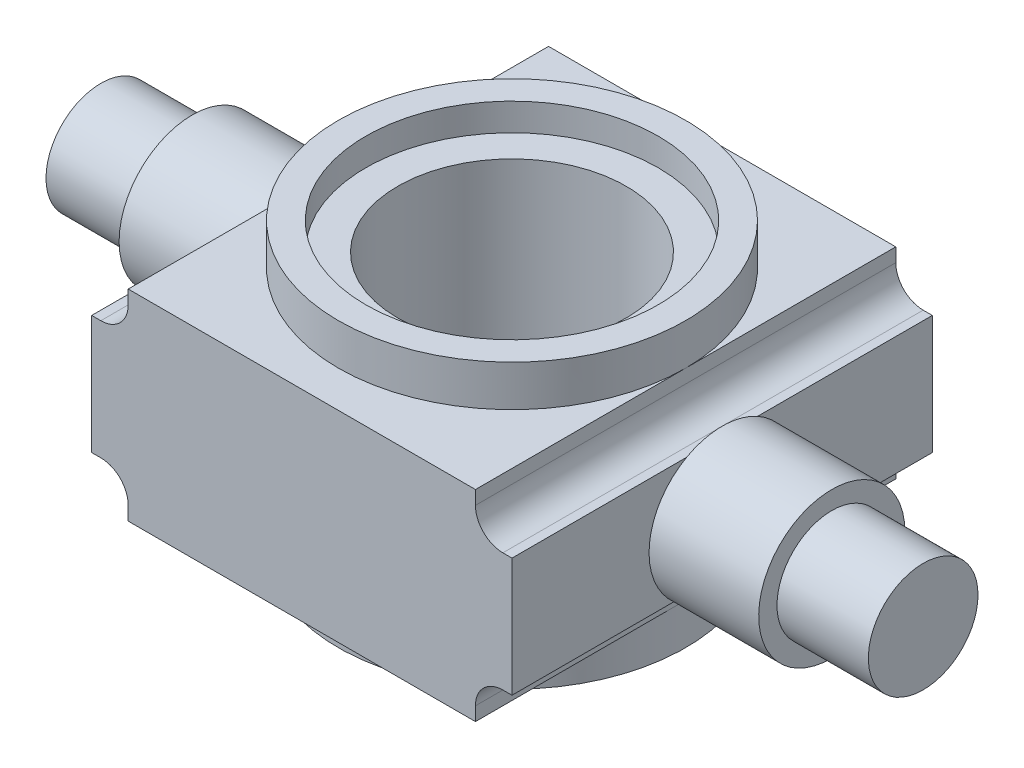
from build123d import *

# Parameters (mm, degrees)
SKETCH1_W           = 46
SKETCH1_H           = 46
BOSS_EXTRUDE1_DEPTH = 22
SKETCH2_R           = 19
BOSS_EXTRUDE4_DEPTH = 4.5
SKETCH5_R           = 19
BOSS_EXTRUDE5_DEPTH = 4.5
SKETCH6_R           = 16
CUT_EXTRUDE1_DEPTH  = 3
SKETCH7_R           = 12.5
CUT_EXTRUDE2_DEPTH  = 29
SKETCH8_R           = 8
BOSS_EXTRUDE6_DEPTH = 12
SKETCH9_R           = 6
BOSS_EXTRUDE7_DEPTH = 10
SKETCH10_R          = 8
BOSS_EXTRUDE8_DEPTH = 12
SKETCH11_R          = 6
BOSS_EXTRUDE9_DEPTH = 10
CUT_EXTRUDE3_DEPTH  = 47


with BuildPart() as part:
    # Sketch1 → Boss-Extrude1 (new body)
    with BuildSketch(Plane(origin=(0, 0, 0), x_dir=(1, 0, 0), z_dir=(0, 1, 0))):
        Rectangle(SKETCH1_W, SKETCH1_H)
    extrude(amount=BOSS_EXTRUDE1_DEPTH)

    # Sketch2 → Boss-Extrude4 (add)
    with BuildSketch(Plane(origin=(0, 22, 0), x_dir=(1, 0, 0), z_dir=(0, 1, 0))):
        Circle(SKETCH2_R)
    extrude(amount=BOSS_EXTRUDE4_DEPTH)

    # Sketch5 → Boss-Extrude5 (add)
    with BuildSketch(Plane.XZ):
        Circle(SKETCH5_R)
    extrude(amount=BOSS_EXTRUDE5_DEPTH)

    # Sketch6 → Cut-Extrude1 (cut)
    with BuildSketch(Plane(origin=(0, 26.5, 0), x_dir=(1, 0, 0), z_dir=(0, 1, 0))):
        Circle(SKETCH6_R)
    extrude(amount=-CUT_EXTRUDE1_DEPTH, mode=Mode.SUBTRACT)

    # Sketch7 → Cut-Extrude2 (cut, through all)
    with BuildSketch(Plane(origin=(0, 23.5, 0), x_dir=(1, 0, 0), z_dir=(0, 1, 0))):
        Circle(SKETCH7_R)
    extrude(amount=-CUT_EXTRUDE2_DEPTH, mode=Mode.SUBTRACT)

    # Sketch8 → Boss-Extrude6 (add)
    with BuildSketch(Plane(origin=(23, 0, 0), x_dir=(0, 0, -1), z_dir=(1, 0, 0))):
        with Locations((0, 10.505702785)):
            Circle(SKETCH8_R)
    extrude(amount=BOSS_EXTRUDE6_DEPTH)

    # Sketch9 → Boss-Extrude7 (add)
    with BuildSketch(Plane(origin=(35, 0, 0), x_dir=(0, 0, -1), z_dir=(1, 0, 0))):
        with Locations((0, 10.505702785)):
            Circle(SKETCH9_R)
    extrude(amount=BOSS_EXTRUDE7_DEPTH)

    # Sketch10 → Boss-Extrude8 (add)
    with BuildSketch(Plane.ZY.offset(23)):
        with Locations((0, 11)):
            Circle(SKETCH10_R)
    extrude(amount=BOSS_EXTRUDE8_DEPTH)

    # Sketch11 → Boss-Extrude9 (add)
    with BuildSketch(Plane.ZY.offset(35)):
        with Locations((0, 11)):
            Circle(SKETCH11_R)
    extrude(amount=BOSS_EXTRUDE9_DEPTH)

    # Sketch13 → Cut-Extrude3 (cut, through all)
    with BuildSketch(Plane.XY.offset(23)):
        with BuildLine():
            Line((-23, 22), (-19, 22))
            Line((-19, 22), (-19, 20.5))
            ThreePointArc((-19, 20.5), (-19.878679656, 18.378679656), (-22, 17.5))
            Line((-22, 17.5), (-23, 17.5))
            Line((-23, 17.5), (-23, 22))
        make_face()
        with BuildLine():
            Line((23, 22), (19, 22))
            Line((19, 22), (19, 20.5))
            ThreePointArc((19, 20.5), (19.878679656, 18.378679656), (22, 17.5))
            Line((22, 17.5), (23, 17.5))
            Line((23, 17.5), (23, 22))
        make_face()
        with BuildLine():
            Line((-23, 0), (-19, 0))
            Line((-19, 0), (-19, 1.5))
            ThreePointArc((-19, 1.5), (-19.878679656, 3.621320344), (-22, 4.5))
            Line((-22, 4.5), (-23, 4.5))
            Line((-23, 4.5), (-23, 0))
        make_face()
        with BuildLine():
            Line((23, 0), (23, 4.5))
            Line((23, 4.5), (22, 4.5))
            ThreePointArc((22, 4.5), (19.878679656, 3.621320344), (19, 1.5))
            Line((19, 1.5), (19, 0))
            Line((19, 0), (23, 0))
        make_face()
    extrude(amount=-CUT_EXTRUDE3_DEPTH, mode=Mode.SUBTRACT)


solid = part.part
